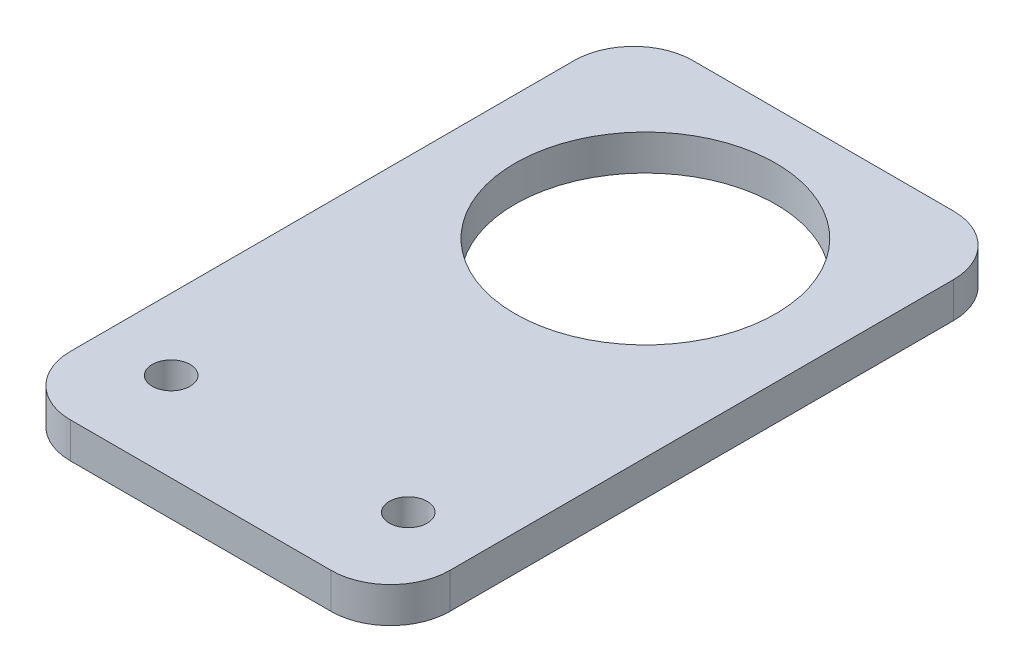
from build123d import *

# Parameters (mm, degrees)
SKETCH1_W           = 32
SKETCH1_H           = 52.5
SKETCH1_R           = 11
SKETCH1_R_2         = 1.6
BOSS_EXTRUDE1_DEPTH = 3
FILLET1_R           = 5


with BuildPart() as part:
    # Sketch1 → Boss-Extrude1 (new body)
    with BuildSketch(Plane(origin=(0, 0, 0), x_dir=(1, 0, 0), z_dir=(0, 1, 0))):
        with Locations((16, 26.25)):
            Rectangle(SKETCH1_W, SKETCH1_H)
        with Locations((16, 37.5)):
            Circle(SKETCH1_R, mode=Mode.SUBTRACT)
        with Locations((6, 7.5)):
            Circle(SKETCH1_R_2, mode=Mode.SUBTRACT)
        with Locations((26, 7.5)):
            Circle(SKETCH1_R_2, mode=Mode.SUBTRACT)
    extrude(amount=BOSS_EXTRUDE1_DEPTH)

    # Fillet1
    fillet1_edges = [part.edges().sort_by_distance(p)[0] for p in [
        (0, 1.5, -52.5),
        (32, 1.5, -52.5),
        (32, 1.5, 0),
        (0, 1.5, 0),
    ]]
    fillet(fillet1_edges, radius=FILLET1_R)


solid = part.part
